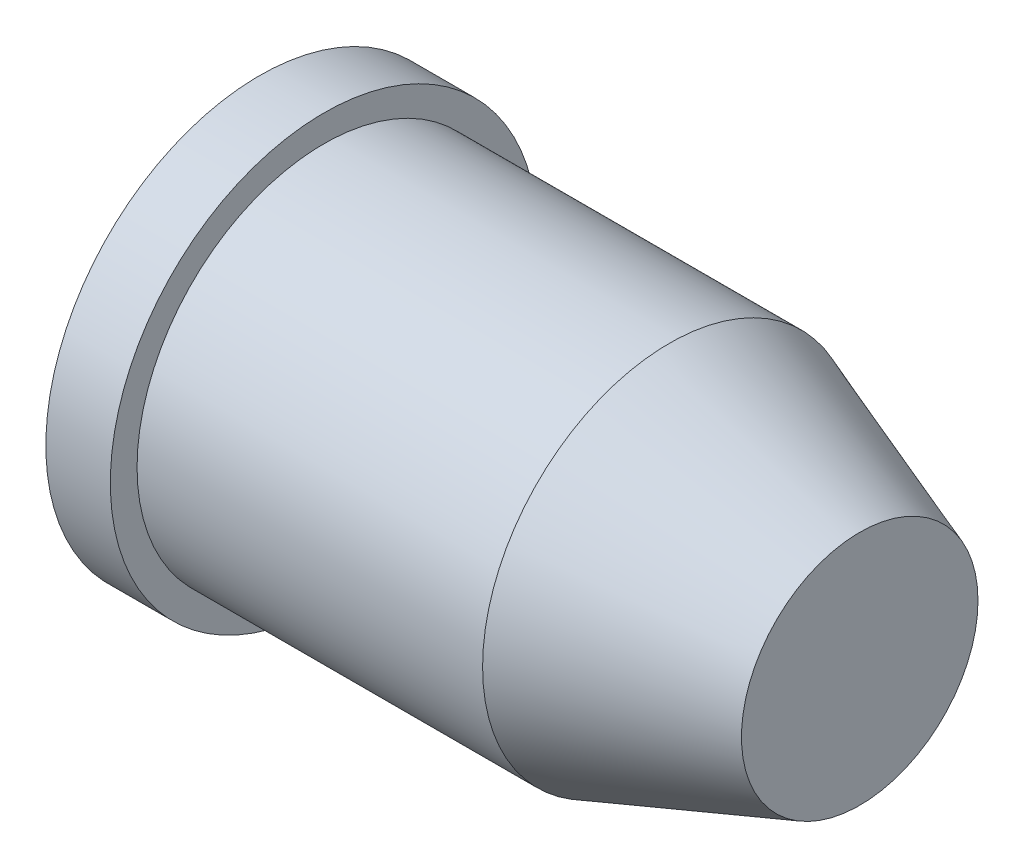
from build123d import *


with BuildPart() as part:
    # Sketch2 → Revolve1 (revolve)
    with BuildSketch(Plane.XY):
        Polygon((0, 63.752601219), (0, 33.84218192), (115.53199326, 33.84218192), (160.25519164, 16.180791476), (160.25519164, 0), (179.143057778, 0), (179.143057778, 35.296075155), (122.368660528, 55.776489406), (19.24892923, 55.776489406), (19.24892923, 63.752601219), align=None)
    revolve(axis=Axis((113.972001836, 0, 0), (-1, 0, 0)))


solid = part.part
